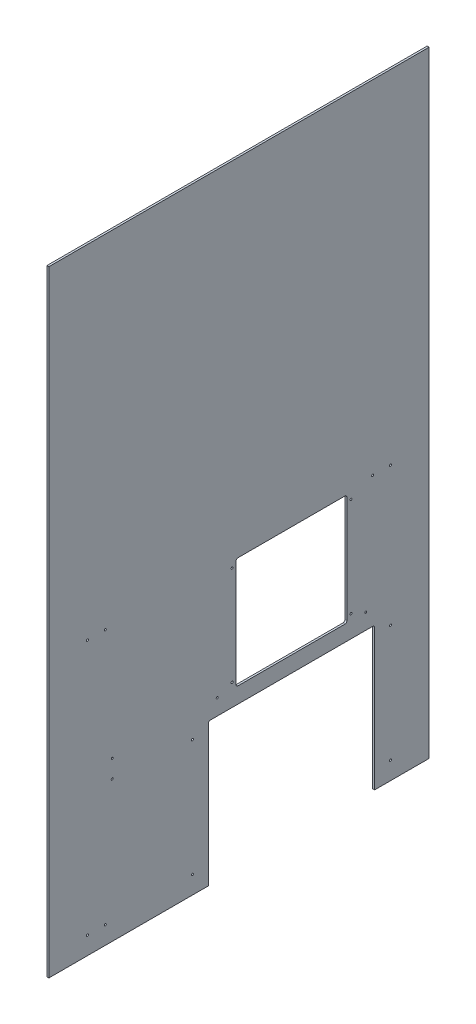
from build123d import *

# Parameters (mm, degrees)
SKETCH1_W                   = 1219.2
SKETCH1_H                   = 1974.85
BOSS_EXTRUDE1_DEPTH         = 6.35
SKETCH2_W                   = 533.4
SKETCH2_H                   = 457.2
SKETCH2_W_2                 = 355.6
SKETCH2_H_2                 = 355.6
CUT_EXTRUDE1_DEPTH          = 7.35
FILLET1_R                   = 6.35
F_1_4_0_25_DIAMETER_HOLE1_D = 6.35


with BuildPart() as part:
    # Sketch1 → Boss-Extrude1 (new body)
    with BuildSketch(Plane(origin=(0, 0, 0), x_dir=(0, 0, -1), z_dir=(1, 0, 0))):
        with Locations((609.6, 987.425)):
            Rectangle(SKETCH1_W, SKETCH1_H)
    extrude(amount=BOSS_EXTRUDE1_DEPTH)

    # Sketch2 → Cut-Extrude1 (cut, through all)
    with BuildSketch(Plane(origin=(6.35, 0, 0), x_dir=(0, 0, -1), z_dir=(1, 0, 0))):
        with Locations((777.875, 228.6)):
            Rectangle(SKETCH2_W, SKETCH2_H)
        with Locations((777.875, 685.8)):
            Rectangle(SKETCH2_W_2, SKETCH2_H_2)
    extrude(amount=-CUT_EXTRUDE1_DEPTH, mode=Mode.SUBTRACT)

    # Fillet1
    fillet1_edges = [part.edges().sort_by_distance(p)[0] for p in [
        (3.175, 457.2, -1044.575),
        (3.175, 457.2, -511.175),
        (3.175, 863.6, -955.675),
        (3.175, 508, -955.675),
        (3.175, 508, -600.075),
        (3.175, 863.6, -600.075),
    ]]
    fillet(fillet1_edges, radius=FILLET1_R)

    # 1/4 (0.25) Diameter Hole1 (through all)
    with Locations(Plane(origin=(6.35, 0, 0), x_dir=(0, 0, -1), z_dir=(1, 0, 0))):
        with Locations((1095.375, 57.15), (1095.375, 431.8), (1095.375, 876.3), (968.375, 844.55), (587.375, 844.55), (587.375, 527.05), (968.375, 527.05), (1016, 508), (1038.225, 876.3), (539.75, 508), (460.375, 431.8), (460.375, 57.15), (180.975, 876.3), (203.2, 508), (203.2, 450.85), (123.825, 876.3), (180.975, 57.15), (123.825, 57.15)):
            Hole(F_1_4_0_25_DIAMETER_HOLE1_D / 2)


solid = part.part
